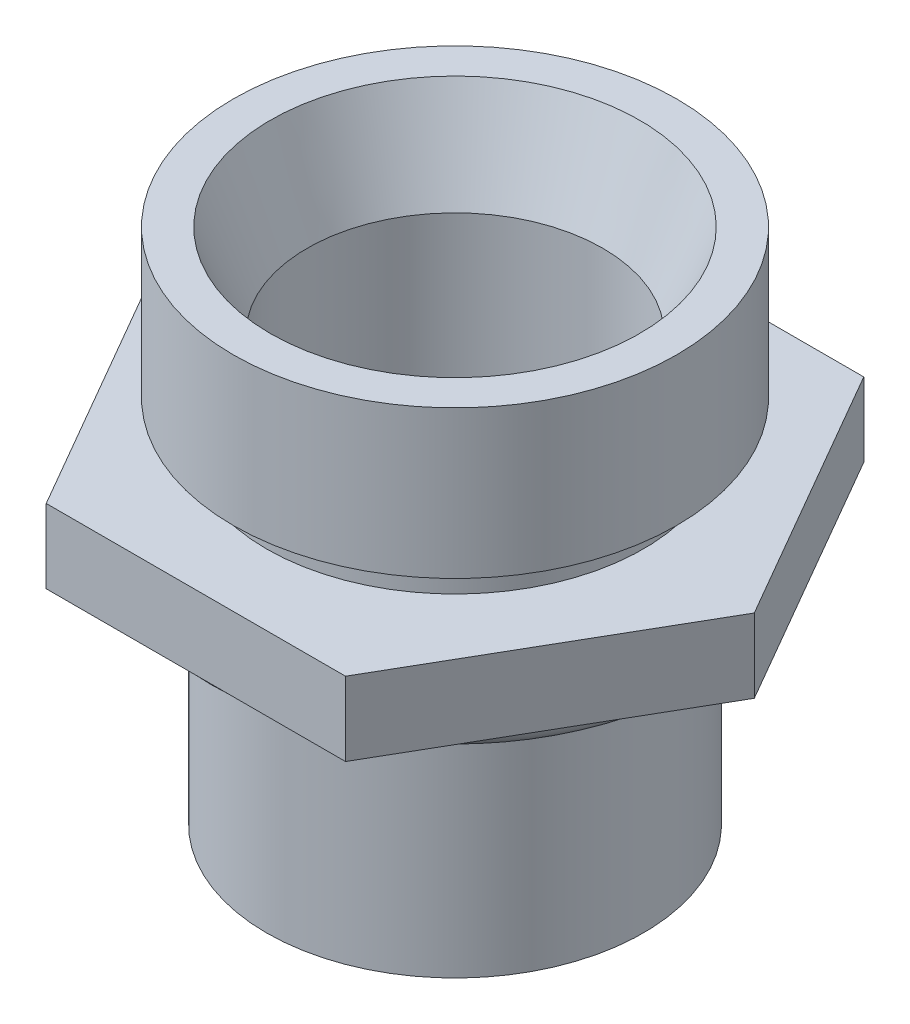
from build123d import *

# Parameters (mm, degrees)
SKETCH_1_R          = 0.8
SKETCH_3_R          = 12.642414599
CUT_EXTRUDE_2_DEPTH = 10


with BuildPart() as part:
    # Эскиз1 → Повернуть1 (revolve)
    with BuildSketch(Plane.XY):
        with Locations((-6, 1.537505723)):
            Circle(SKETCH_1_R)
        Polygon((-5.1, 3.437505723), (-8.1, 3.437505723), (-8.1, 1.437505723), (-6.9, 1.437505723), (-6.9, 2.437505723), (-5.1, 2.437505723), (-5.1, 1.437505723), (-5.1, -5.562494277), (-4, -5.562494277), (-4, 5.937505723), (-5, 8.437505723), (-6, 8.437505723), (-6, 4.437505723), (-5.1, 4.437505723), align=None)
    revolve(axis=Axis((0, 12.440414794, 0), (0, -1, 0)))

    # Эскиз3 → Вырез-Вытянуть2 (cut)
    with BuildSketch(Plane(origin=(0, 3.437505723, 0), x_dir=(1, 0, 0), z_dir=(0, 1, 0))):
        with Locations((0.002, 0)):
            Circle(SKETCH_3_R)
        Polygon((-8.1, 0), (-4.050366025, 7.013439745), (4.048633975, 7.014439745), (8.1, 0), (4.050366025, -7.013439745), (-4.048633975, -7.014439745), align=None, mode=Mode.SUBTRACT)
    extrude(amount=-CUT_EXTRUDE_2_DEPTH, mode=Mode.SUBTRACT)


solid = part.part
